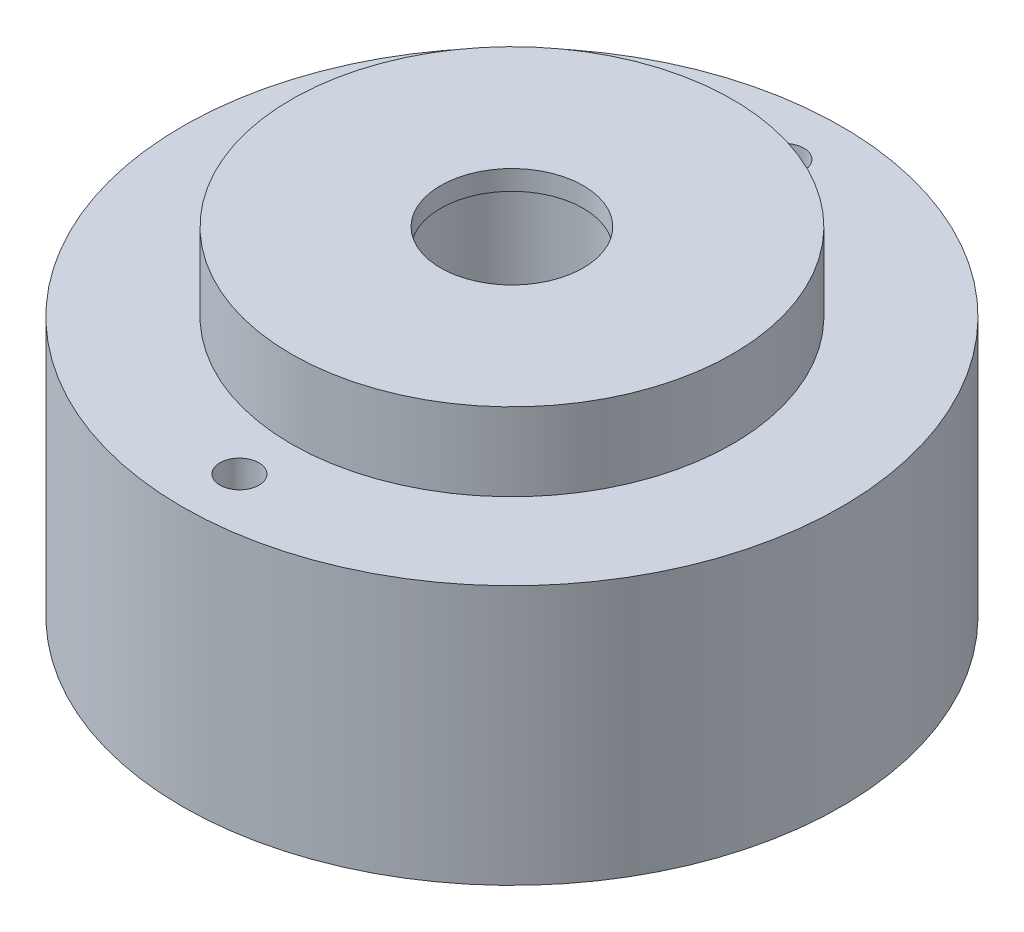
from build123d import *

# Parameters (mm, degrees)
SKETCH1_R                      = 12.7
BOSS_EXTRUDE1_DEPTH            = 10
SKETCH2_R                      = 8.5
BOSS_EXTRUDE2_DEPTH            = 3
F_5_5_5_5_DIAMETER_HOLE1_D     = 5.5
F_6_3_6_3_DIAMETER_HOLE1_D     = 6.3
F_6_3_6_3_DIAMETER_HOLE1_DEPTH = 12
F_6_3_6_3_DIAMETER_HOLE1_TIP   = 1.89271095
F_1_5MM_DOWEL_HOLE1_D          = 1.5
F_1_5MM_DOWEL_HOLE1_DEPTH      = 3
F_1_5MM_DOWEL_HOLE1_TIP        = 0.450645464


with BuildPart() as part:
    # Sketch1 → Boss-Extrude1 (new body)
    with BuildSketch(Plane(origin=(0, 0, 0), x_dir=(1, 0, 0), z_dir=(0, 1, 0))):
        Circle(SKETCH1_R)
    extrude(amount=BOSS_EXTRUDE1_DEPTH)

    # Sketch2 → Boss-Extrude2 (add)
    with BuildSketch(Plane(origin=(0, 10, 0), x_dir=(1, 0, 0), z_dir=(0, 1, 0))):
        Circle(SKETCH2_R)
    extrude(amount=BOSS_EXTRUDE2_DEPTH)

    # Ø5.5 (5.5) Diameter Hole1 (through all)
    with Locations(Plane(origin=(0, 0, 0), x_dir=(-1, 0, 0), z_dir=(0, -1, 0))):
        with Locations((0, 0)):
            Hole(F_5_5_5_5_DIAMETER_HOLE1_D / 2)

    # Ø6.3 (6.3) Diameter Hole1
    with Locations(Plane(origin=(0, 0, 0), x_dir=(-1, 0, 0), z_dir=(0, -1, 0))):
        with Locations((0, 0)):
            Hole(F_6_3_6_3_DIAMETER_HOLE1_D / 2, depth=F_6_3_6_3_DIAMETER_HOLE1_DEPTH)
            with Locations((0, 0, -(F_6_3_6_3_DIAMETER_HOLE1_DEPTH + F_6_3_6_3_DIAMETER_HOLE1_TIP / 2))):  # 118° drill point
                Cone(0, F_6_3_6_3_DIAMETER_HOLE1_D / 2, F_6_3_6_3_DIAMETER_HOLE1_TIP, mode=Mode.SUBTRACT)

    # Ø1.5mm Dowel Hole1
    with Locations(Plane(origin=(0, 10, 0), x_dir=(1, 0, 0), z_dir=(0, 1, 0))):
        with Locations((0, 10.5), (0, -10.5)):
            Hole(F_1_5MM_DOWEL_HOLE1_D / 2, depth=F_1_5MM_DOWEL_HOLE1_DEPTH)
            with Locations((0, 0, -(F_1_5MM_DOWEL_HOLE1_DEPTH + F_1_5MM_DOWEL_HOLE1_TIP / 2))):  # 118° drill point
                Cone(0, F_1_5MM_DOWEL_HOLE1_D / 2, F_1_5MM_DOWEL_HOLE1_TIP, mode=Mode.SUBTRACT)


solid = part.part
